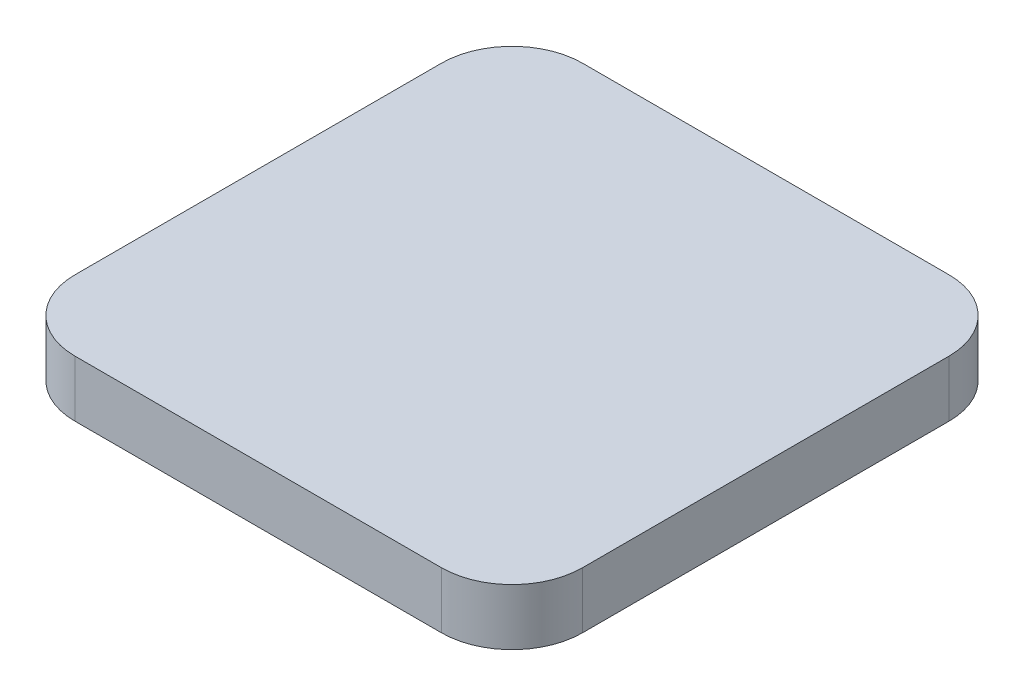
from build123d import *

# Parameters (mm, degrees)
SKETCH1_W           = 36
SKETCH1_H           = 36
BOSS_EXTRUDE1_DEPTH = 4
FILLET1_R           = 5


with BuildPart() as part:
    # Sketch1 → Boss-Extrude1 (new body)
    with BuildSketch(Plane(origin=(0, 0, 0), x_dir=(1, 0, 0), z_dir=(0, 1, 0))):
        with Locations((18, 18)):
            Rectangle(SKETCH1_W, SKETCH1_H)
    extrude(amount=BOSS_EXTRUDE1_DEPTH)

    # Fillet1
    fillet1_edges = [part.edges().sort_by_distance(p)[0] for p in [
        (0, 2, -36),
        (36, 2, -36),
        (36, 2, 0),
        (0, 2, 0),
    ]]
    fillet(fillet1_edges, radius=FILLET1_R)


solid = part.part
